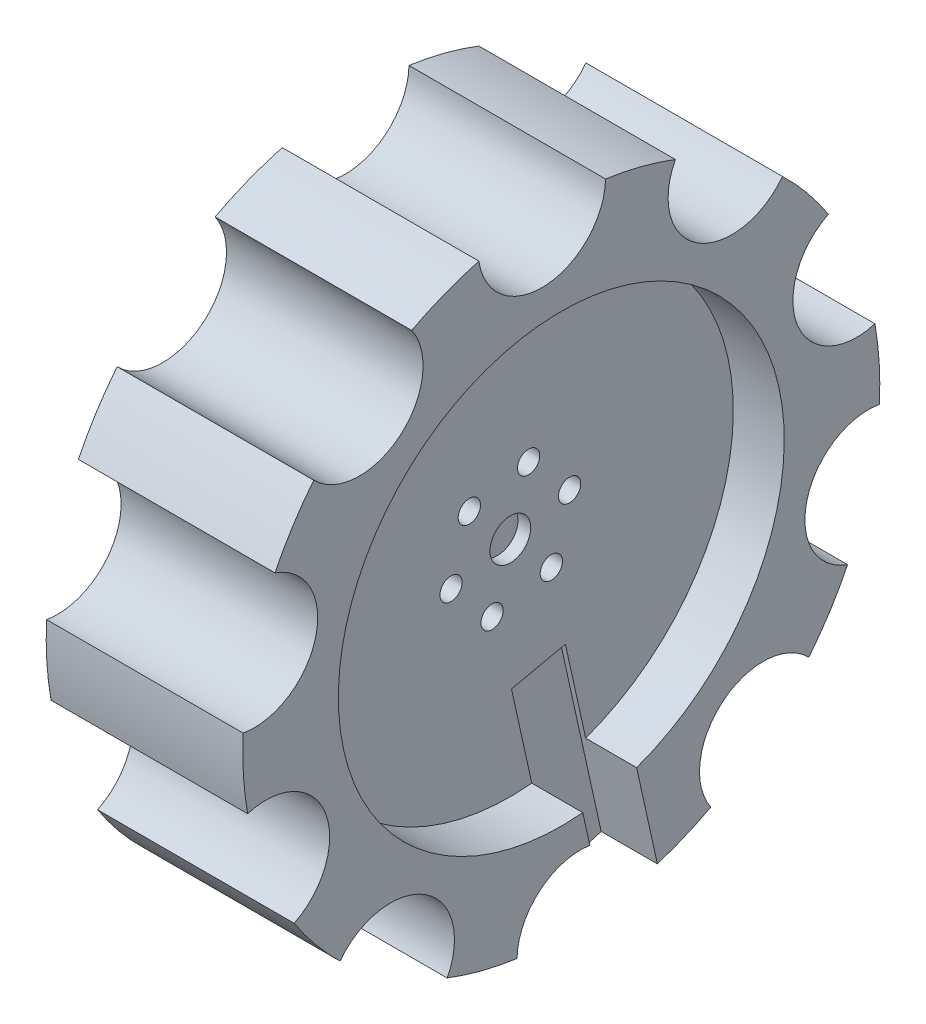
from build123d import *

# Parameters (mm, degrees)
SKETCH1_R           = 50
BOSS_EXTRUDE1_DEPTH = 30.86
SKETCH2_R           = 35
CUT_EXTRUDE1_DEPTH  = 8
CUT_EXTRUDE4_START  = -20
SKETCH10_W          = 10.01875972
SKETCH10_H          = 8.661840267
CUT_EXTRUDE4_DEPTH  = 60
SKETCH12_R          = 3.2
CUT_EXTRUDE5_DEPTH  = 2
SKETCH5_R           = 1.75
CUT_EXTRUDE3_DEPTH  = 30
SKETCH8_R           = 4
CUT_EXTRUDE6_DEPTH  = 10
SKETCH13_R          = 10
CUT_EXTRUDE8_DEPTH  = 40


with BuildPart() as part:
    # Sketch1 → Boss-Extrude1 (new body)
    with BuildSketch(Plane(origin=(0, 0, 0), x_dir=(0, 0, -1), z_dir=(1, 0, 0))):
        Circle(SKETCH1_R)
    extrude(amount=BOSS_EXTRUDE1_DEPTH)

    # Sketch2 → Cut-Extrude1 (cut)
    with BuildSketch(Plane(origin=(30.86, 0, 0), x_dir=(0, 0, -1), z_dir=(1, 0, 0))):
        Circle(SKETCH2_R)
    extrude(amount=-CUT_EXTRUDE1_DEPTH, mode=Mode.SUBTRACT)

    # Sketch10 → Cut-Extrude4 (cut)
    with BuildSketch(Plane(origin=(0, 0, 0), x_dir=(1, 0, 0), z_dir=(0, 0.976356599, 0.21616612)).offset(CUT_EXTRUDE4_START)):
        with Locations((27.048757514, 0.091052199)):
            Rectangle(SKETCH10_W, SKETCH10_H)
    extrude(amount=-CUT_EXTRUDE4_DEPTH, mode=Mode.SUBTRACT)

    # Sketch12 → Cut-Extrude5 (cut)
    with BuildSketch(Plane(origin=(22.86, 0, 0), x_dir=(0, 0, -1), z_dir=(1, 0, 0))):
        Circle(SKETCH12_R)
    extrude(amount=-CUT_EXTRUDE5_DEPTH, mode=Mode.SUBTRACT)

    # Sketch5 → Cut-Extrude3 (cut)
    with BuildSketch(Plane.ZY):
        with Locations((2.868272201, -9.088119419)):
            Circle(SKETCH5_R)
        with Locations((-6.436406189, -7.028056301)):
            Circle(SKETCH5_R)
        with Locations((-9.30467839, 2.060063119)):
            Circle(SKETCH5_R)
        with Locations((-2.868272201, 9.088119419)):
            Circle(SKETCH5_R)
        with Locations((6.436406189, 7.028056301)):
            Circle(SKETCH5_R)
        with Locations((9.30467839, -2.060063119)):
            Circle(SKETCH5_R)
    extrude(amount=-CUT_EXTRUDE3_DEPTH, mode=Mode.SUBTRACT)

    # Sketch8 → Cut-Extrude6 (cut)
    with BuildSketch(Plane.ZY):
        with Locations((-2.868272201, 9.088119419)):
            Circle(SKETCH8_R)
        with Locations((6.436406189, 7.028056301)):
            Circle(SKETCH8_R)
        with Locations((9.30467839, -2.060063119)):
            Circle(SKETCH8_R)
        with Locations((2.868272201, -9.088119419)):
            Circle(SKETCH8_R)
        with Locations((-6.436406189, -7.028056301)):
            Circle(SKETCH8_R)
        with Locations((-9.30467839, 2.060063119)):
            Circle(SKETCH8_R)
    extrude(amount=-CUT_EXTRUDE6_DEPTH, mode=Mode.SUBTRACT)

    # Sketch13 → Cut-Extrude8 (cut)
    with BuildSketch(Plane.ZY):
        with Locations((48.2405892, 12.470792391)):
            Circle(SKETCH13_R)
        with Locations((46.357604333, -18.266023916)):
            Circle(SKETCH13_R)
        with Locations((26.767590248, -42.025839926)):
            Circle(SKETCH13_R)
        with Locations((-3.046733515, -49.733213491)):
            Circle(SKETCH13_R)
        with Locations((-31.69730863, -38.444189871)):
            Circle(SKETCH13_R)
        with Locations((-48.2405892, -12.470792391)):
            Circle(SKETCH13_R)
        with Locations((-46.357604333, 18.266023916)):
            Circle(SKETCH13_R)
        with Locations((-26.767590248, 42.025839926)):
            Circle(SKETCH13_R)
        with Locations((3.046733515, 49.733213491)):
            Circle(SKETCH13_R)
        with Locations((31.69730863, 38.444189871)):
            Circle(SKETCH13_R)
    extrude(amount=-CUT_EXTRUDE8_DEPTH, mode=Mode.SUBTRACT)


solid = part.part
